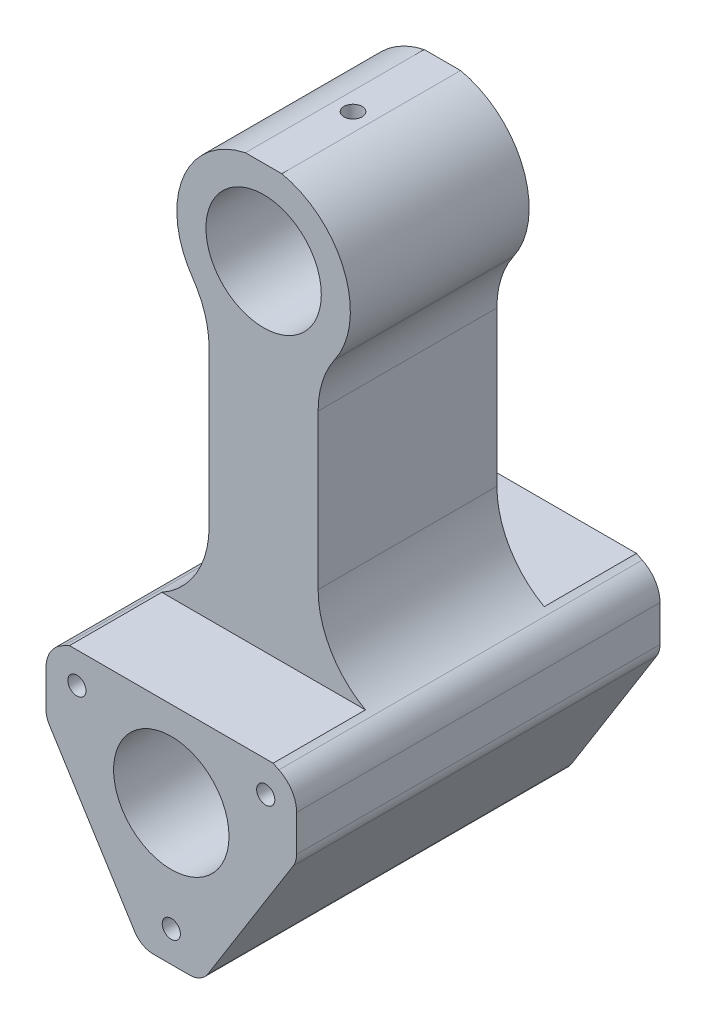
from build123d import *

# Parameters (mm, degrees)
BOSS_EXTRUDE1_DEPTH = 25
SKETCH1_3_R         = 7.9375
BOSS_EXTRUDE2_DEPTH = 12.3
SKETCH3_R           = 1.25
CUT_EXTRUDE1_DEPTH  = 84.203236869
SKETCH4_R           = 1.25
CUT_EXTRUDE2_DEPTH  = 10
SKETCH5_R           = 7.9375
CUT_EXTRUDE3_DEPTH  = 94.796474483


with BuildPart() as part:
    # Sketch1 → Boss-Extrude1 (new, symmetric)
    with BuildSketch(Plane.XY):
        with BuildLine():
            Line((14.011631608, -46.463203436), (-14.011631608, -46.463203436))
            ThreePointArc((-14.011631608, -46.463203436), (-14.401354266, -46.671858143), (-14.798102621, -46.866822962))
            ThreePointArc((-14.798102621, -46.866822962), (-16.578229761, -48.435081034), (-17.240381057, -50.713203436))
            Line((-17.240381057, -50.713203436), (-17.240381057, -55.713203436))
            ThreePointArc((-17.240381057, -55.713203436), (-17.123784168, -56.541446455), (-16.783056724, -57.305309102))
            Line((-16.783056724, -57.305309102), (-5.042675667, -76.055309102))
            ThreePointArc((-5.042675667, -76.055309102), (-3.953217637, -77.087733584), (-2.5, -77.463203436))
            Line((-2.5, -77.463203436), (2.5, -77.463203436))
            ThreePointArc((2.5, -77.463203436), (3.953217637, -77.087733584), (5.042675667, -76.055309102))
            Line((5.042675667, -76.055309102), (16.783056724, -57.305309102))
            ThreePointArc((16.783056724, -57.305309102), (17.123784168, -56.541446455), (17.240381057, -55.713203436))
            Line((17.240381057, -55.713203436), (17.240381057, -50.713203436))
            ThreePointArc((17.240381057, -50.713203436), (16.578229761, -48.435081034), (14.798102621, -46.866822962))
            ThreePointArc((14.798102621, -46.866822962), (14.401354266, -46.671858143), (14.011631608, -46.463203436))
        make_face()
    extrude(amount=BOSS_EXTRUDE1_DEPTH, both=True)

    # Sketch1_3 → Boss-Extrude2 (add, symmetric)
    with BuildSketch(Plane.XY):
        with BuildLine():
            ThreePointArc((-7.5, -35.372933076), (-9.248235791, -41.803241056), (-14.011631608, -46.463203436))
            Line((-14.011631608, -46.463203436), (14.011631608, -46.463203436))
            ThreePointArc((14.011631608, -46.463203436), (9.248235791, -41.803241056), (7.5, -35.372933076))
            Line((7.5, -35.372933076), (7.5, -14.105545231))
            ThreePointArc((7.5, -14.105545231), (8.085343648, -10.294364118), (9.787417555, -6.83449807))
            ThreePointArc((9.787417555, -6.83449807), (11.107431649, 4.373656183), (2.5, 11.672784854))
            Line((2.5, 11.672784854), (-2.5, 11.672784854))
            ThreePointArc((-2.5, 11.672784854), (-11.107431649, 4.373656183), (-9.787417555, -6.83449807))
            ThreePointArc((-9.787417555, -6.83449807), (-8.085343648, -10.294364118), (-7.5, -14.105545231))
            Line((-7.5, -14.105545231), (-7.5, -35.372933076))
        make_face()
        Circle(SKETCH1_3_R, mode=Mode.SUBTRACT)
    extrude(amount=BOSS_EXTRUDE2_DEPTH, both=True)

    # Sketch3 → Cut-Extrude1 (cut, through all)
    with BuildSketch(Plane(origin=(0, 0, 0), x_dir=(1, 0, 0), z_dir=(0, 1, 0))):
        Circle(SKETCH3_R)
    extrude(amount=CUT_EXTRUDE1_DEPTH, mode=Mode.SUBTRACT)

    # Sketch4 → Cut-Extrude2 (cut)
    with BuildSketch(Plane.XY.offset(25)):
        with Locations((-12.990381057, -50.713203436)):
            Circle(SKETCH4_R)
        with Locations((12.990381057, -50.713203436)):
            Circle(SKETCH4_R)
        with Locations((0, -73.213203436)):
            Circle(SKETCH4_R)
    cut_extrude2 = extrude(amount=-CUT_EXTRUDE2_DEPTH, mode=Mode.SUBTRACT)

    # Mirror1: Cut-Extrude2 across plane
    add(cut_extrude2.mirror(Plane.XY), mode=Mode.SUBTRACT)

    # Sketch5 → Cut-Extrude3 (cut, through all)
    with BuildSketch(Plane.XY.offset(25)):
        with Locations((0, -58.213203436)):
            Circle(SKETCH5_R)
    extrude(amount=-CUT_EXTRUDE3_DEPTH, mode=Mode.SUBTRACT)


solid = part.part
